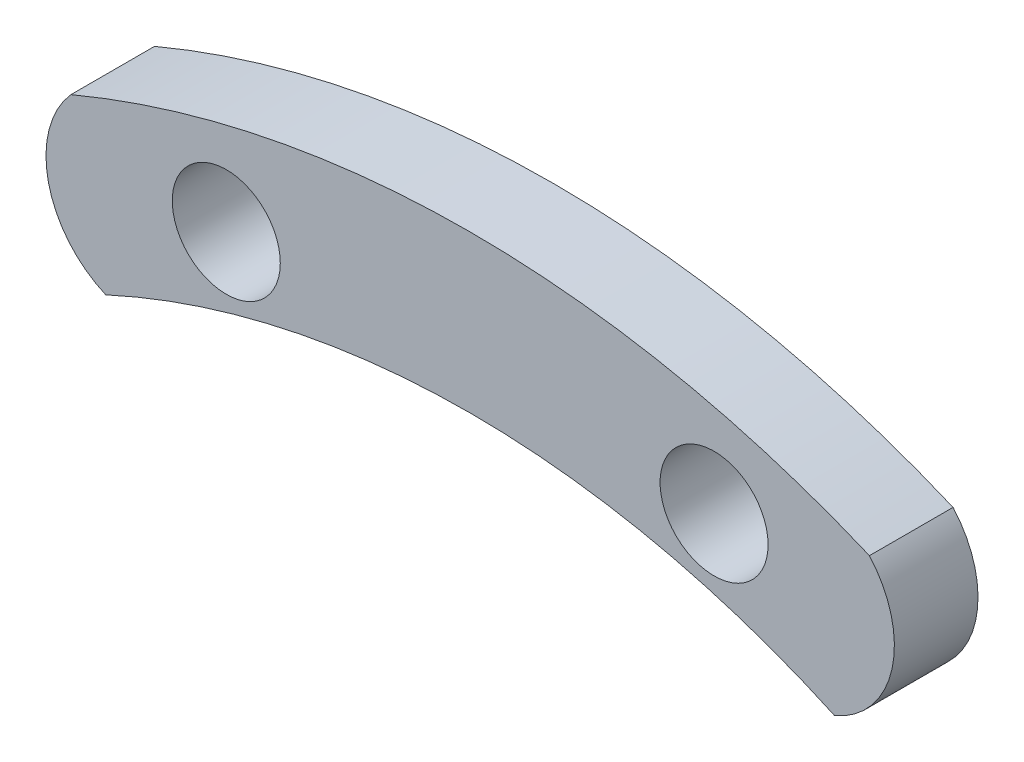
from build123d import *

# Parameters (mm, degrees)
SKETCH2_R           = 3.937
BOSS_EXTRUDE4_DEPTH = 6.096


with BuildPart() as part:
    # Sketch2 → Boss-Extrude4 (new body)
    with BuildSketch(Plane.XY):
        with BuildLine():
            ThreePointArc((29.104915692, 69.046424835), (0, 74.93), (-29.104915692, 69.046424835))
            ThreePointArc((-29.104915692, 69.046424835), (-30.750210185, 62.710204346), (-26.565512441, 57.676022304))
            ThreePointArc((-26.565512441, 57.676022304), (0, 63.5), (26.565512441, 57.676022304))
            ThreePointArc((26.565512441, 57.676022304), (30.750210185, 62.710204346), (29.104915692, 69.046424835))
        make_face()
        with Locations((17.78, 66.04)):
            Circle(SKETCH2_R, mode=Mode.SUBTRACT)
        with Locations((-17.78, 66.04)):
            Circle(SKETCH2_R, mode=Mode.SUBTRACT)
    extrude(amount=BOSS_EXTRUDE4_DEPTH)


solid = part.part
